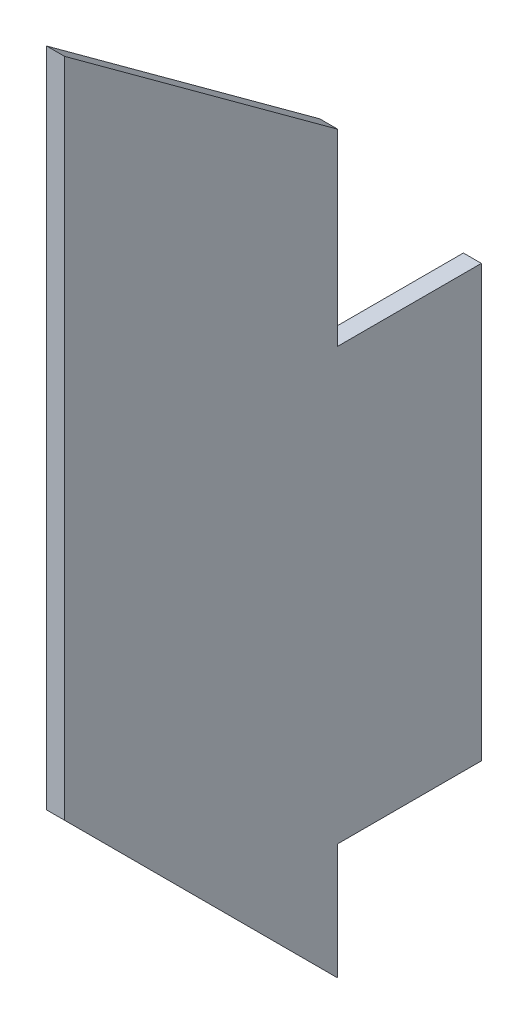
from build123d import *

# Parameters (mm, degrees)
BOSS_EXTRUDE1_DEPTH = 3.18


with BuildPart() as part:
    # Sketch2 → Boss-Extrude1 (new body)
    with BuildSketch(Plane.YZ):
        Polygon((0, 0), (48.3, 48.3), (165.3, 48.3), (130, 0), (96.75, 0), (96.75, -25.4), (20.55, -25.4), (20.55, 0), align=None)
    extrude(amount=BOSS_EXTRUDE1_DEPTH)


solid = part.part
